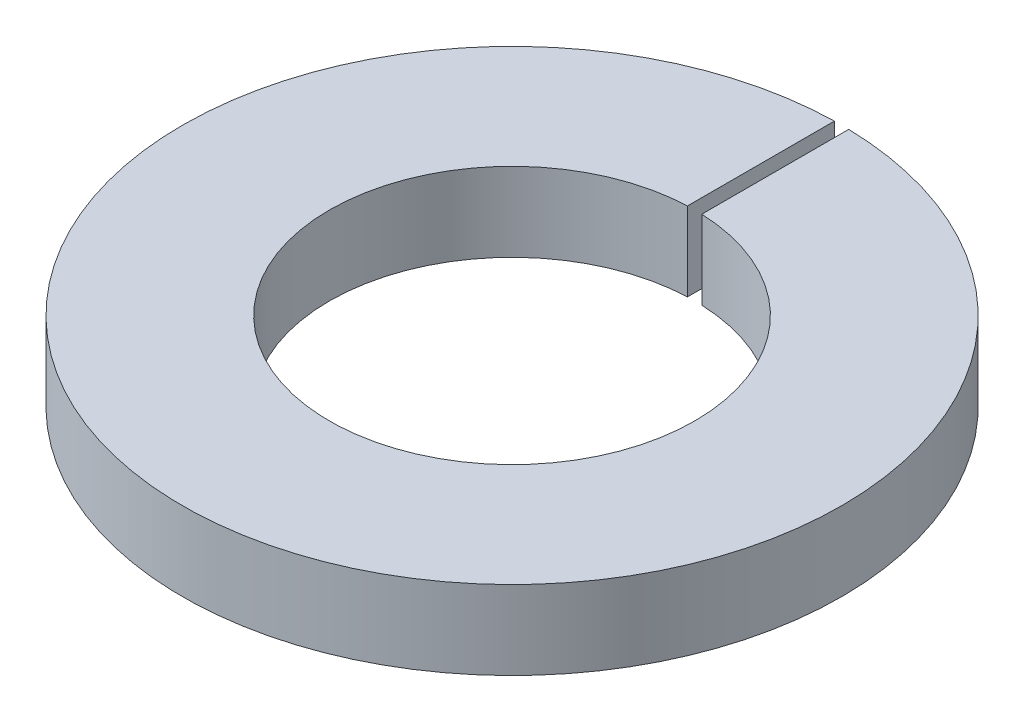
from build123d import *

# Parameters (mm, degrees)
RESSALTO_EXTRUS_O1_DEPTH = 1.1


with BuildPart() as part:
    # Esboço1 → Ressalto-extrusão1 (new body)
    with BuildSketch(Plane(origin=(0, 0, 0), x_dir=(1, 0, 0), z_dir=(0, 1, 0))):
        with BuildLine():
            Line((-0.1, 4.598912915), (-0.1, 2.548038461))
            ThreePointArc((-0.1, 2.548038461), (0, -2.55), (0.1, 2.548038461))
            Line((0.1, 2.548038461), (0.1, 4.598912915))
            ThreePointArc((0.1, 4.598912915), (0, -4.6), (-0.1, 4.598912915))
        make_face()
    extrude(amount=RESSALTO_EXTRUS_O1_DEPTH)


solid = part.part
